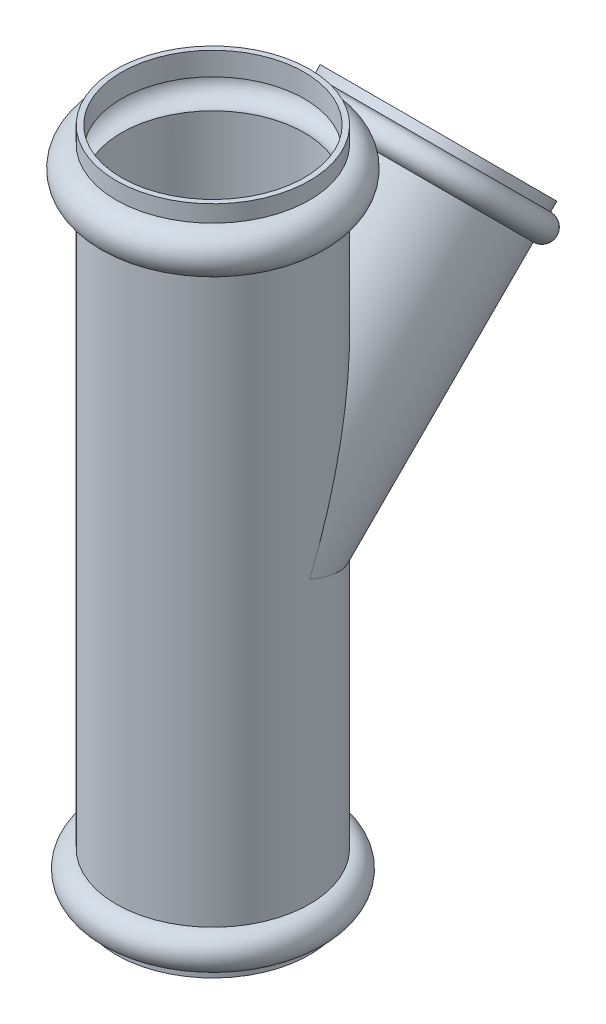
from build123d import *


with BuildPart() as part:
    # Эскиз2 → Повернуть-Тонкостенный1 (revolve)
    with BuildSketch(Plane.XY):
        with BuildLine():
            Line((55, 196.449193069), (55, 186.898243866))
            ThreePointArc((55, 186.898243866), (66.898243866, 175), (55, 163.101756134))
            Line((55, 163.101756134), (55, -160))
            ThreePointArc((55, -160), (65.00000002, -169.99999998), (55.00000004, -180))
            Line((55.00000004, -180), (55.00000004, -185))
            Line((55.00000004, -185), (52.00000004, -185))
            Line((52.00000004, -185), (52.00000004, -176.32455533))
            ThreePointArc((52.00000004, -176.32455533), (62.00000002, -169.999999978), (52, -163.675444689))
            Line((52, -163.675444689), (52, 166.622724554))
            ThreePointArc((52, 166.622724554), (63.898243866, 175), (52, 183.377275446))
            Line((52, 183.377275446), (52, 196.449193069))
            Line((52, 196.449193069), (55, 196.449193069))
        make_face()
    revolve(axis=Axis((0, 137.813713198, 0), (0, -1, 0)))

    # Эскиз3 → Повернуть-Тонкостенный3 (revolve)
    with BuildSketch(Plane(origin=(0, 0, 0), x_dir=(1, 0, 0), z_dir=(0, 0.707106781, 0.707106781))):
        with BuildLine():
            Line((55, 181.514689721), (55, 176.514689721))
            ThreePointArc((55, 176.514689721), (62, 169.514689721), (55, 162.514689721))
            Line((55, 162.514689721), (55, 0))
            Line((55, 0), (53, 0))
            Line((53, 0), (53, 164.932114026))
            ThreePointArc((53, 164.932114026), (60, 169.514689721), (53, 174.097265416))
            Line((53, 174.097265416), (53, 181.514689721))
            Line((53, 181.514689721), (55, 181.514689721))
        make_face()
    revolve(axis=Axis((0, 88.670134299, -88.670134299), (0, -0.707106781, 0.707106781)))


solid = part.part
